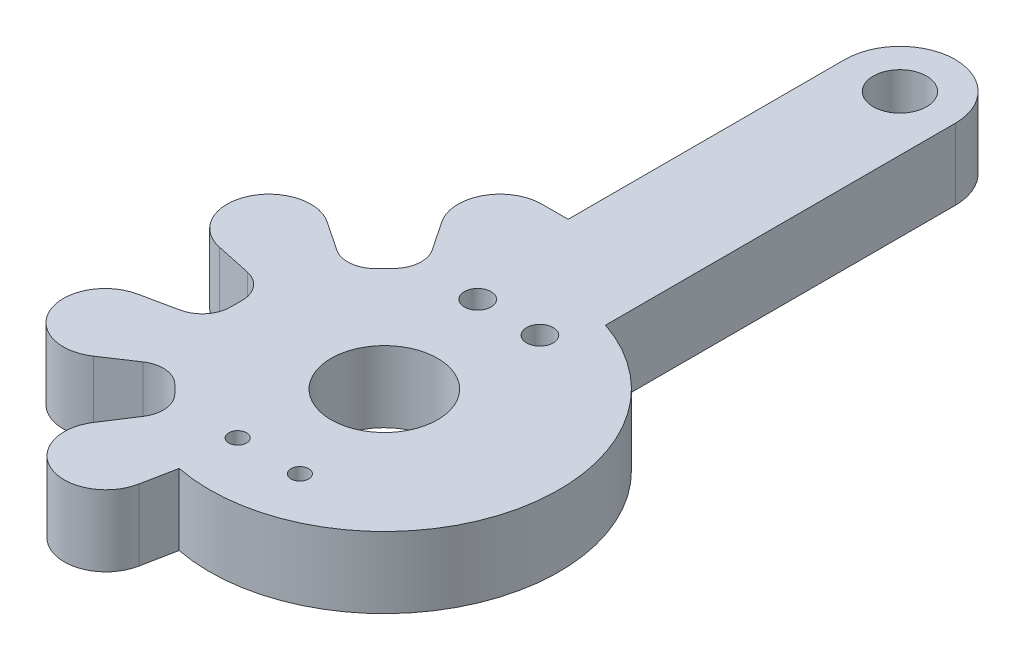
from build123d import *

# Parameters (mm, degrees)
CROQUIS1_R              = 1.49817269
CROQUIS1_R_2            = 2.996164088
CROQUIS1_R_3            = 0.749999538
CROQUIS1_R_4            = 0.749999677
CROQUIS1_R_5            = 0.500000135
CROQUIS1_R_6            = 0.499999787
SALIENTE_EXTRUIR1_DEPTH = 4


with BuildPart() as part:
    # Croquis1 → Saliente-Extruir1 (new body)
    with BuildSketch(Plane(origin=(0, 0, 0), x_dir=(1, 0, 0), z_dir=(0, 1, 0))):
        with BuildLine():
            Line((-2.771145689, 3.732352208), (-1.295728101, 3.732352208))
            Line((-1.295728101, 3.732352208), (-1.295728101, 19.296313944))
            ThreePointArc((-1.295728101, 19.296313944), (1.809273381, 22.401315426), (4.914274862, 19.296313944))
            Line((4.914274862, 19.296313944), (4.914274862, -0.374323426))
            ThreePointArc((4.914274862, -0.374323426), (11.296230277, -12.207784547), (-0.100533102, -19.340381653))
            Line((-0.100533102, -19.340381653), (-0.473678479, -21.235402092))
            ThreePointArc((-0.473678479, -21.235402092), (-3.656560928, -22.956227452), (-4.742951437, -19.504889123))
            Line((-4.742951437, -19.504889123), (-3.638068078, -17.802867047))
            ThreePointArc((-3.638068078, -17.802867047), (-3.393654936, -16.784225076), (-3.844679826, -15.838738006))
            Line((-3.844679826, -15.838738006), (-4.320831306, -15.362586526))
            ThreePointArc((-4.320831306, -15.362586526), (-5.27515607, -14.910658594), (-6.299806788, -15.165738025))
            Line((-6.299806788, -15.165738025), (-7.976088157, -16.28110044))
            ThreePointArc((-7.976088157, -16.28110044), (-11.450003687, -15.233750996), (-9.768409722, -12.018588215))
            Line((-9.768409722, -12.018588215), (-7.77884303, -11.596670181))
            ThreePointArc((-7.77884303, -11.596670181), (-6.868732518, -11.039395013), (-6.512384859, -10.033475979))
            Line((-6.512384859, -10.033475979), (-6.512384859, -9.385437189))
            ThreePointArc((-6.512384859, -9.385437189), (-6.862343771, -8.397552686), (-7.756137447, -7.850268577))
            Line((-7.756137447, -7.850268577), (-9.756013297, -7.426164328))
            ThreePointArc((-9.756013297, -7.426164328), (-11.437933851, -4.204098724), (-7.955506206, -3.163300372))
            Line((-7.955506206, -3.163300372), (-6.292102369, -4.277795727))
            ThreePointArc((-6.292102369, -4.277795727), (-5.254751387, -4.534795839), (-4.293390141, -4.067965387))
            Line((-4.293390141, -4.067965387), (-3.797367558, -3.557739732))
            ThreePointArc((-3.797367558, -3.557739732), (-3.359699549, -2.605638888), (-3.61887602, -1.590317826))
            Line((-3.61887602, -1.590317826), (-4.728201004, 0.065299063))
            ThreePointArc((-4.728201004, 0.065299063), (-4.849446935, 2.48575952), (-2.771145689, 3.732352208))
        make_face()
        with Locations((1.806542391, 19.29086522)):
            Circle(CROQUIS1_R, mode=Mode.SUBTRACT)
        with Locations((1.80610831, -9.704394827)):
            Circle(CROQUIS1_R_2, mode=Mode.SUBTRACT)
        with Locations((0.059270172, -2.708668348)):
            Circle(CROQUIS1_R_3, mode=Mode.SUBTRACT)
        with Locations((3.559270137, -2.708669201)):
            Circle(CROQUIS1_R_4, mode=Mode.SUBTRACT)
        with Locations((0.059269976, -16.208667718)):
            Circle(CROQUIS1_R_5, mode=Mode.SUBTRACT)
        with Locations((3.559270485, -16.208667851)):
            Circle(CROQUIS1_R_6, mode=Mode.SUBTRACT)
    extrude(amount=SALIENTE_EXTRUIR1_DEPTH)


solid = part.part
